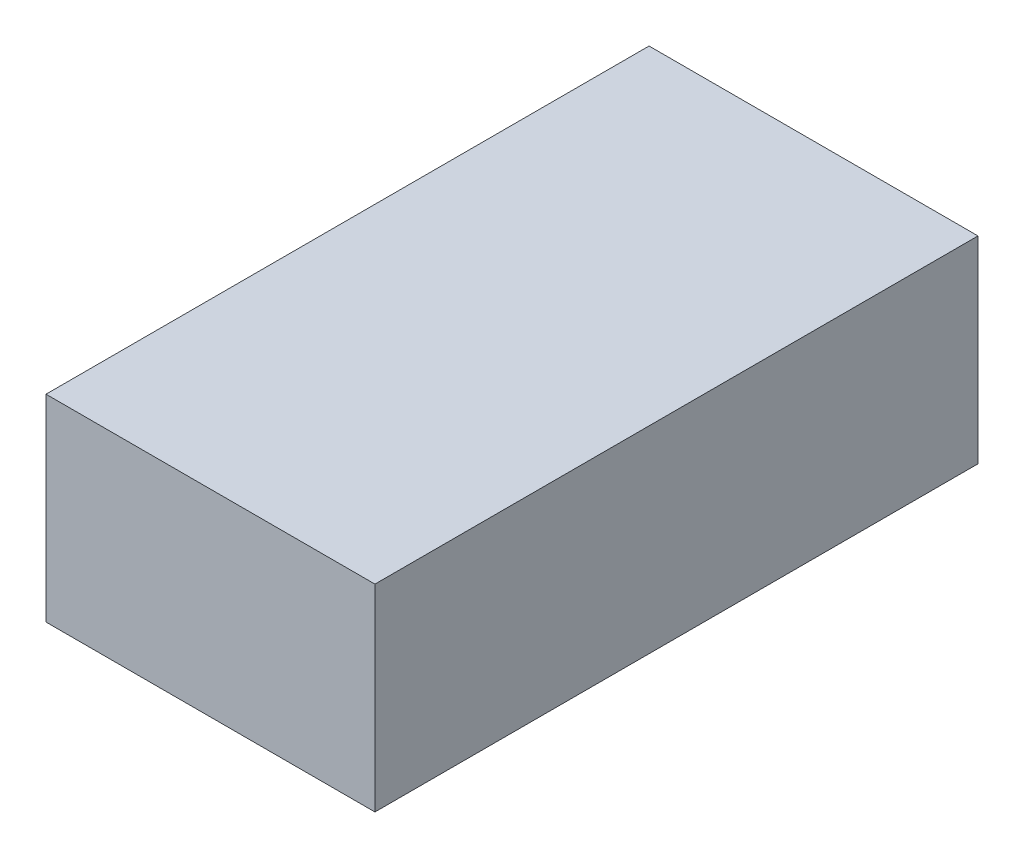
from build123d import *

# Parameters (mm, degrees)
SKETCH_1_W      = 30
SKETCH_1_H      = 55
EXTRUDE_1_DEPTH = 18


with BuildPart() as part:
    # 草图1 → 凸台-拉伸1 (new body)
    with BuildSketch(Plane(origin=(0, 0, 0), x_dir=(1, 0, 0), z_dir=(0, 1, 0))):
        Rectangle(SKETCH_1_W, SKETCH_1_H)
    extrude(amount=EXTRUDE_1_DEPTH)


solid = part.part
